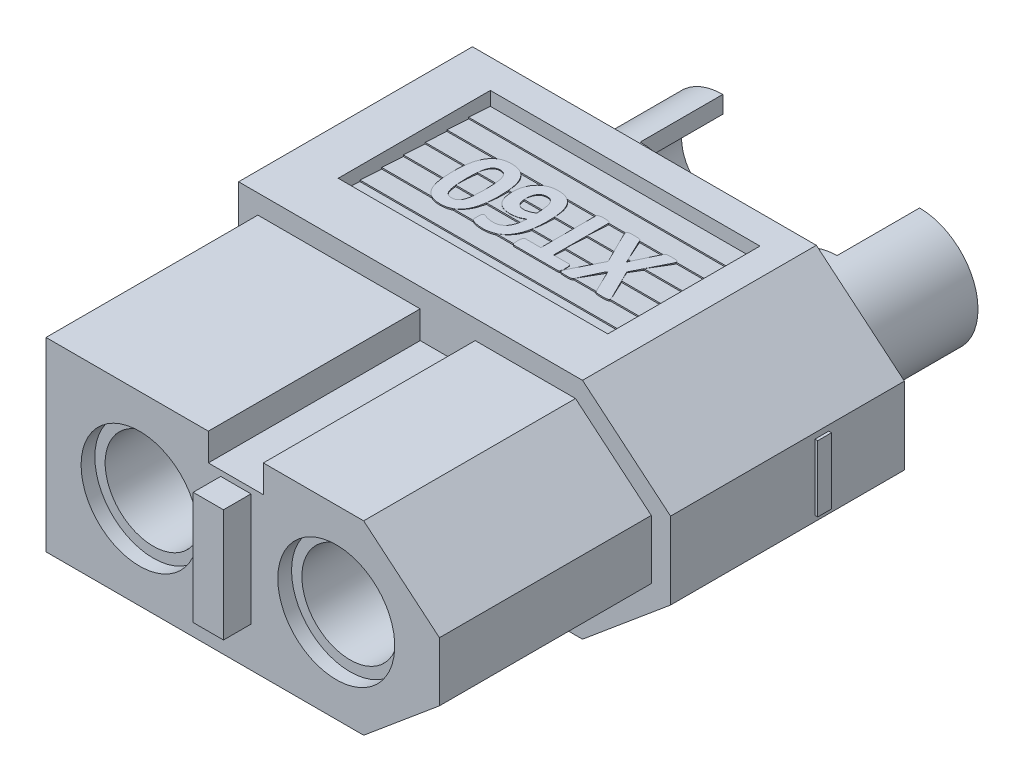
from build123d import *

# Parameters (mm, degrees)
RESSALTO_EXTRUS_O1_DEPTH         = 16.2
ESBO_O3_W                        = 0.5
ESBO_O3_H                        = 2.4
RESSALTO_EXTRUS_O2_DEPTH         = 0.1
RESSALTO_EXTRUS_O2_DEPTH_BACK    = 15.8
ESBO_O4_W                        = 2.4
ESBO_O4_H                        = 0.5
RESSALTO_EXTRUS_O3_DEPTH         = 0.1
ESBO_O5_R                        = 2.925
CORTE_EXTRUS_O2_DEPTH            = 3.5
ESBO_O6_R                        = 2.125
CORTE_EXTRUS_O3_DEPTH            = 21.676934613
ESBO_O7_R                        = 2.125
RESSALTO_EXTRUS_O4_DEPTH         = 5
RESSALTO_EXTRUS_O4_DEPTH_BACK    = 15.7
FURO_DE_DI_METRO_3_0_3_1_D       = 3
FURO_DE_DI_METRO_3_0_3_1_DEPTH   = 3.6
FURO_DE_DI_METRO_3_0_3_1_TIP     = 0.901290929
ESBO_O10_W                       = 2.125
ESBO_O10_H                       = 3
CORTE_EXTRUS_O4_DEPTH            = 28.667715844
CORTE_EXTRUS_O5_START            = -1.7
CORTE_EXTRUS_O5_DEPTH            = 9.8
RESSALTO_EXTRUS_O6_DEPTH         = 0.05
RESSALTO_EXTRUS_O7_DEPTH         = 0.05
ESBO_O2_OUTSIDE_W                = 23.444
ESBO_O2_OUTSIDE_H                = 15.694
CORTE_EXTRUS_O7_DEPTH            = 7.7
ESBO_O16_W                       = 2
ESBO_O16_H                       = 1
CORTE_EXTRUS_O8_DEPTH            = 7.7
ESBO_O17_W                       = 1.1
ESBO_O17_H                       = 4.1
RESSALTO_EXTRUS_O8_DEPTH         = 1
FURO_DE_DI_METRO_3_5_3_5_1_D     = 3.5
FURO_DE_DI_METRO_3_5_3_5_1_DEPTH = 12
FURO_DE_DI_METRO_3_5_3_5_1_TIP   = 1.051506083


with BuildPart() as part:
    # Esboço1 → Ressalto-extrusão1 (new body)
    with BuildSketch(Plane.XY):
        Polygon((0, 0), (0, 4.075), (12.5, 4.075), (15.7, 1.4), (15.7, -1.4), (12.5, -4.075), (0, -4.075), align=None)
    extrude(amount=-RESSALTO_EXTRUS_O1_DEPTH)

    # Esboço3 → Ressalto-extrusão2 (add, two sides)
    with BuildSketch(Plane(origin=(15.7, 0, 0), x_dir=(0, 0, -1), z_dir=(1, 0, 0))) as ressalto_extrus_o2_sk:
        with Locations((13.2, 0)):
            Rectangle(ESBO_O3_W, ESBO_O3_H)
    extrude(amount=RESSALTO_EXTRUS_O2_DEPTH)
    extrude(ressalto_extrus_o2_sk.sketch, amount=-RESSALTO_EXTRUS_O2_DEPTH_BACK)

    # Esboço4 → Ressalto-extrusão3 (add)
    with BuildSketch(Plane.ZY):
        with Locations((-13.2, 0)):
            Rectangle(ESBO_O4_W, ESBO_O4_H)
    extrude(amount=RESSALTO_EXTRUS_O3_DEPTH)

    # Esboço5 → Corte-extrusão2 (cut)
    with BuildSketch(Plane(origin=(0, 0, -16.2), x_dir=(-1, 0, 0), z_dir=(0, 0, -1))):
        with Locations((-4.1, 0)):
            Circle(ESBO_O5_R)
        with Locations((-11.25, 0)):
            Circle(ESBO_O5_R)
    extrude(amount=-CORTE_EXTRUS_O2_DEPTH, mode=Mode.SUBTRACT)

    # Esboço6 → Corte-extrusão3 (cut, through all)
    with BuildSketch(Plane(origin=(0, 0, -12.7), x_dir=(-1, 0, 0), z_dir=(0, 0, -1))):
        with Locations((-11.25, 0)):
            Circle(ESBO_O6_R)
        with Locations((-4.1, 0)):
            Circle(ESBO_O6_R)
    extrude(amount=-CORTE_EXTRUS_O3_DEPTH, mode=Mode.SUBTRACT)

    # Esboço7 → Ressalto-extrusão4 (add, two sides)
    with BuildSketch(Plane(origin=(0, 0, -16.2), x_dir=(-1, 0, 0), z_dir=(0, 0, -1))) as ressalto_extrus_o4_sk:
        with Locations((-11.25, 0)):
            Circle(ESBO_O7_R)
        with Locations((-4.1, 0)):
            Circle(ESBO_O7_R)
    extrude(amount=RESSALTO_EXTRUS_O4_DEPTH)
    extrude(ressalto_extrus_o4_sk.sketch, amount=-RESSALTO_EXTRUS_O4_DEPTH_BACK)

    # Furo de diâmetro Ø3.0 (3)1
    with Locations(Plane(origin=(0, 0, -21.2), x_dir=(-1, 0, 0), z_dir=(0, 0, -1))):
        with Locations((-11.25, 0), (-4.1, 0)):
            Hole(FURO_DE_DI_METRO_3_0_3_1_D / 2, depth=FURO_DE_DI_METRO_3_0_3_1_DEPTH)
            with Locations((0, 0, -(FURO_DE_DI_METRO_3_0_3_1_DEPTH + FURO_DE_DI_METRO_3_0_3_1_TIP / 2))):  # 118° drill point
                Cone(0, FURO_DE_DI_METRO_3_0_3_1_D / 2, FURO_DE_DI_METRO_3_0_3_1_TIP, mode=Mode.SUBTRACT)

    # Esboço10 → Corte-extrusão4 (cut, through all)
    with BuildSketch(Plane(origin=(0, 4.075, 0), x_dir=(1, 0, 0), z_dir=(0, 1, 0))):
        with Locations((5.1625, 19.7)):
            Rectangle(ESBO_O10_W, ESBO_O10_H)
        with Locations((10.1875, 19.7)):
            Rectangle(ESBO_O10_W, ESBO_O10_H)
    extrude(amount=-CORTE_EXTRUS_O4_DEPTH, mode=Mode.SUBTRACT)

    # Esboço12 → Corte-extrusão5 (cut)
    with BuildSketch(Plane.ZY.offset(CORTE_EXTRUS_O5_START)):
        Polygon((-9.62, 4.075), (-15.15, 4.075), (-15.15, 3.575), (-14.36, 3.625), (-14.36, 3.575), (-13.57, 3.625), (-13.57, 3.575), (-12.78, 3.625), (-12.78, 3.575), (-11.99, 3.625), (-11.99, 3.575), (-11.2, 3.625), (-11.2, 3.575), (-10.41, 3.625), (-10.41, 3.575), (-9.62, 3.625), align=None)
    corte_extrus_o5 = extrude(amount=-CORTE_EXTRUS_O5_DEPTH, mode=Mode.SUBTRACT)

    # Espelhar1: Corte-extrusão5 across plane
    add(corte_extrus_o5.mirror(Plane.ZX), mode=Mode.SUBTRACT)

    # Esboço13 → Ressalto-extrusão6 (add)
    with BuildSketch(Plane(origin=(0, 3.575, 0), x_dir=(-1, 0, 0), z_dir=(0, 1, 0))):
        with BuildLine():
            add(Edge.make_bspline(
                [(-8.234641561, -13.445571688), (-8.229912114, -13.456153044), (-8.221000453, -13.476091412), (-8.208478692, -13.504296034), (-8.200539268, -13.529795764), (-8.193533814, -13.551501719), (-8.190606852, -13.570582286), (-8.190490698, -13.587635432), (-8.196029978, -13.602281593), (-8.204820877, -13.614842908), (-8.218088126, -13.624787378), (-8.235701708, -13.631860331), (-8.257272865, -13.637319606), (-8.283106651, -13.641242536), (-8.313646706, -13.643111213), (-8.34918968, -13.644848276), (-8.390224184, -13.645936797), (-8.419343109, -13.646201883), (-8.434845735, -13.646343013)],
                knots=[0, 0, 0, 0, 1.33881063, 2.522710567, 3.55823117, 4.421855077, 5.150490164, 5.783956486, 6.364012369, 6.927396487, 7.534352519, 8.24811931, 9.105929366, 10.100125022, 11.260442172, 12.637334165, 14.209750218, 16, 16, 16, 16], degree=3))
            add(Edge.make_bspline(
                [(-8.434845735, -13.646343013), (-8.45941607, -13.646007312), (-8.502710711, -13.645415784), (-8.560169388, -13.644108333), (-8.603722632, -13.638747313), (-8.636957534, -13.632327533), (-8.661538298, -13.62129635), (-8.679434231, -13.607094039), (-8.690987949, -13.588492014), (-8.696684049, -13.575151575), (-8.699705082, -13.568076225)],
                knots=[0, 0, 0, 0, 1.993677762, 3.512999033, 4.656089022, 5.552580678, 6.245508647, 6.822733668, 7.375614965, 8, 8, 8, 8], degree=3))
            Line((-8.699705082, -13.568076225), (-9.126202359, -12.674246824))
            Line((-9.126202359, -12.674246824), (-9.550998185, -13.568076225))
            add(Edge.make_bspline(
                [(-9.550998185, -13.568076225), (-9.554420482, -13.575156296), (-9.560855848, -13.588469824), (-9.572973852, -13.606730658), (-9.590400819, -13.621679404), (-9.615386313, -13.63210906), (-9.649006335, -13.638918578), (-9.69283172, -13.643968922), (-9.749683634, -13.645447394), (-9.792039641, -13.646020654), (-9.815857532, -13.646343013)],
                knots=[0, 0, 0, 0, 0.639550826, 1.202626028, 1.769676174, 2.478488857, 3.377444042, 4.554208722, 6.062341394, 8, 8, 8, 8], degree=3))
            add(Edge.make_bspline(
                [(-9.815857532, -13.646343013), (-9.830225613, -13.646198262), (-9.857264839, -13.645925857), (-9.895090158, -13.644886263), (-9.927788964, -13.643062345), (-9.955524818, -13.641330223), (-9.978882569, -13.637259243), (-9.998091686, -13.631952073), (-10.013573976, -13.624632212), (-10.025108673, -13.614746389), (-10.031959847, -13.601974011), (-10.036249426, -13.587467177), (-10.035705984, -13.570541497), (-10.032114996, -13.55148655), (-10.024728617, -13.529689189), (-10.015315431, -13.504435401), (-10.002587861, -13.475953754), (-9.992874513, -13.456125899), (-9.987704174, -13.445571688)],
                knots=[0, 0, 0, 0, 1.743948978, 3.281929376, 4.591588072, 5.719618763, 6.651354855, 7.464517483, 8.131494618, 8.716472262, 9.271430783, 9.867110125, 10.532506743, 11.302095744, 12.216435998, 13.320169609, 14.573547416, 16, 16, 16, 16], degree=3))
            Line((-9.987704174, -13.445571688), (-9.443806715, -12.364015426))
            Line((-9.443806715, -12.364015426), (-9.949137931, -11.347681488))
            add(Edge.make_bspline(
                [(-9.949137931, -11.347681488), (-9.954164514, -11.336763312), (-9.963626085, -11.316211953), (-9.975233503, -11.286701032), (-9.985307445, -11.261179787), (-9.992096331, -11.238841367), (-9.996985023, -11.21935776), (-9.996364215, -11.202215642), (-9.99249125, -11.187523225), (-9.983979844, -11.175352273), (-9.970702, -11.166484928), (-9.953902201, -11.158918283), (-9.932679067, -11.154320623), (-9.907258464, -11.150985155), (-9.876940002, -11.148999489), (-9.841213652, -11.147101222), (-9.799785428, -11.146975079), (-9.770295344, -11.146562515), (-9.754605263, -11.146343013)],
                knots=[0, 0, 0, 0, 1.381015555, 2.599495016, 3.644671344, 4.531245376, 5.285471223, 5.937655438, 6.480840598, 7.011274188, 7.602323543, 8.29283132, 9.120186307, 10.085039733, 11.239867224, 12.610244907, 14.196494385, 16, 16, 16, 16], degree=3))
            add(Edge.make_bspline(
                [(-9.754605263, -11.146343013), (-9.741558686, -11.146222788), (-9.716782999, -11.145994479), (-9.681822233, -11.147509103), (-9.651171449, -11.148360726), (-9.617850166, -11.150555873), (-9.583543752, -11.154240133), (-9.549847026, -11.161459034), (-9.524097746, -11.170598647), (-9.507151713, -11.18604274), (-9.495569929, -11.204494949), (-9.489213995, -11.217916691), (-9.485775862, -11.225176951)],
                knots=[0, 0, 0, 0, 1.305784148, 2.479707747, 3.50232644, 4.374698542, 5.823003153, 6.947851878, 7.830021634, 8.513661778, 9.195991011, 10, 10, 10, 10], degree=3))
            Line((-9.485775862, -11.225176951), (-9.087636116, -12.044142468))
            Line((-9.087636116, -12.044142468), (-8.699705082, -11.225176951))
            add(Edge.make_bspline(
                [(-8.699705082, -11.225176951), (-8.696208396, -11.217958809), (-8.689789069, -11.204707514), (-8.678987166, -11.185825159), (-8.662466375, -11.171432078), (-8.639135192, -11.161047964), (-8.607924012, -11.15443418), (-8.566580132, -11.149301561), (-8.512000017, -11.146989484), (-8.470764909, -11.146577323), (-8.447323049, -11.146343013)],
                knots=[0, 0, 0, 0, 0.679172131, 1.24684586, 1.824338574, 2.496513618, 3.384423394, 4.51265828, 6.017471582, 8, 8, 8, 8], degree=3))
            add(Edge.make_bspline(
                [(-8.447323049, -11.146343013), (-8.433523531, -11.146564201), (-8.407247474, -11.146985373), (-8.37035379, -11.147085854), (-8.338029755, -11.149027992), (-8.310179351, -11.1510601), (-8.286413928, -11.154219396), (-8.266298471, -11.159046466), (-8.250419325, -11.166827939), (-8.238191654, -11.176899845), (-8.230116772, -11.189188032), (-8.225150971, -11.20379148), (-8.224991298, -11.220836902), (-8.228948714, -11.239976481), (-8.23555094, -11.261794984), (-8.243997203, -11.287162685), (-8.254845117, -11.316345412), (-8.263479068, -11.336751762), (-8.268103448, -11.347681488)],
                knots=[0, 0, 0, 0, 1.674249213, 3.187985698, 4.474062261, 5.601505857, 6.57446085, 7.381029521, 8.09893875, 8.700896638, 9.279693563, 9.859851831, 10.548217011, 11.317405471, 12.224627673, 13.312424426, 14.560523399, 16, 16, 16, 16], degree=3))
            Line((-8.268103448, -11.347681488), (-8.773434664, -12.35834392))
            Line((-8.773434664, -12.35834392), (-8.234641561, -13.445571688))
        make_face()
        with BuildLine():
            add(Edge.make_bspline(
                [(-6.479764065, -11.364696007), (-6.479952581, -11.381903542), (-6.48029899, -11.413523441), (-6.48341703, -11.456960547), (-6.489204855, -11.492569091), (-6.495811812, -11.521038206), (-6.505603936, -11.542938637), (-6.518024204, -11.557935573), (-6.532518904, -11.56780598), (-6.543152743, -11.568899092), (-6.548389292, -11.569437387)],
                knots=[0, 0, 0, 0, 1.770192918, 3.252837809, 4.474195287, 5.478923574, 6.253187412, 6.915561504, 7.465976934, 8, 8, 8, 8], degree=3))
            Line((-6.548389292, -11.569437387), (-7.116674229, -11.569437387))
            Line((-7.116674229, -11.569437387), (-7.116674229, -13.565807623))
            add(Edge.make_bspline(
                [(-7.116674229, -13.565807623), (-7.117228597, -13.571945061), (-7.118341807, -13.584269468), (-7.127428288, -13.601786712), (-7.144220624, -13.615719697), (-7.167710509, -13.627021375), (-7.199523817, -13.634947595), (-7.239867569, -13.641788815), (-7.290547162, -13.645274662), (-7.327651728, -13.645963771), (-7.348071688, -13.646343013)],
                knots=[0, 0, 0, 0, 0.55099044, 1.106427587, 1.720983746, 2.48178517, 3.435218407, 4.660203207, 6.161991303, 8, 8, 8, 8], degree=3))
            add(Edge.make_bspline(
                [(-7.348071688, -13.646343013), (-7.368489053, -13.645949995), (-7.405777292, -13.645232225), (-7.456673966, -13.641874277), (-7.497321774, -13.634790597), (-7.529307091, -13.627297057), (-7.552592782, -13.615549041), (-7.569288598, -13.601800063), (-7.578367211, -13.584266302), (-7.579481428, -13.571944008), (-7.580036298, -13.565807623)],
                knots=[0, 0, 0, 0, 1.833840391, 3.349143282, 4.571350014, 5.538985911, 6.282919168, 6.896081612, 7.450259118, 8, 8, 8, 8], degree=3))
            Line((-7.580036298, -13.565807623), (-7.580036298, -11.569437387))
            Line((-7.580036298, -11.569437387), (-8.148321234, -11.569437387))
            add(Edge.make_bspline(
                [(-8.148321234, -11.569437387), (-8.1539353, -11.568946373), (-8.164948634, -11.567983132), (-8.179836964, -11.558248445), (-8.190916127, -11.542485604), (-8.201009403, -11.52112794), (-8.207465206, -11.492536286), (-8.21330788, -11.456972208), (-8.216406773, -11.413519579), (-8.216756267, -11.381902181), (-8.216946461, -11.364696007)],
                knots=[0, 0, 0, 0, 0.571323018, 1.120786752, 1.757624666, 2.530549763, 3.533540823, 4.752786512, 6.232867835, 8, 8, 8, 8], degree=3))
            add(Edge.make_bspline(
                [(-8.216946461, -11.364696007), (-8.216767768, -11.34692021), (-8.216440394, -11.314354056), (-8.213226949, -11.269611506), (-8.207725367, -11.233383291), (-8.20080363, -11.204762743), (-8.191287548, -11.183614648), (-8.179599375, -11.168727226), (-8.164803722, -11.159803236), (-8.153919584, -11.158779661), (-8.148321234, -11.158253176)],
                knots=[0, 0, 0, 0, 1.808148228, 3.312618493, 4.558353409, 5.533285709, 6.298922035, 6.899726023, 7.434064622, 8, 8, 8, 8], degree=3))
            Line((-8.148321234, -11.158253176), (-6.548389292, -11.158253176))
            add(Edge.make_bspline(
                [(-6.548389292, -11.158253176), (-6.543166887, -11.158822375), (-6.532660107, -11.159967528), (-6.518239485, -11.169045028), (-6.505244254, -11.183137353), (-6.49601287, -11.204856282), (-6.488944489, -11.233347393), (-6.48349821, -11.269624422), (-6.480265258, -11.314349754), (-6.479941037, -11.346918691), (-6.479764065, -11.364696007)],
                knots=[0, 0, 0, 0, 0.528901719, 1.064079353, 1.691187204, 2.458025756, 3.434488925, 4.682179932, 6.189012562, 8, 8, 8, 8], degree=3))
        make_face()
        with BuildLine():
            add(Edge.make_bspline(
                [(-4.844555354, -12.808094374), (-4.845247025, -12.838744217), (-4.846612474, -12.899251075), (-4.856275338, -12.988233606), (-4.872679949, -13.073820368), (-4.895953873, -13.155374701), (-4.925117155, -13.232653385), (-4.961282618, -13.304391043), (-5.002446968, -13.371456777), (-5.051124238, -13.432064114), (-5.104840545, -13.487492071), (-5.165252856, -13.536042443), (-5.231195633, -13.578629077), (-5.302881701, -13.615100212), (-5.380529825, -13.644444145), (-5.464224836, -13.664259535), (-5.553460591, -13.677335616), (-5.614885533, -13.678591325), (-5.646506352, -13.67923775)],
                knots=[0, 0, 0, 0, 1.10131412, 2.174140236, 3.212046795, 4.22920211, 5.218361909, 6.175388662, 7.112262148, 8.040623825, 8.963000514, 9.88076228, 10.819186251, 11.779270414, 12.766024375, 13.794191409, 14.864476351, 16, 16, 16, 16], degree=3))
            add(Edge.make_bspline(
                [(-5.646506352, -13.67923775), (-5.672045734, -13.678869754), (-5.721537896, -13.678156624), (-5.793253674, -13.670756192), (-5.859789209, -13.658257146), (-5.921656832, -13.641492467), (-5.97856069, -13.618979437), (-6.031835642, -13.592865549), (-6.08110806, -13.562363994), (-6.126246028, -13.527477715), (-6.167456271, -13.488525554), (-6.204783911, -13.445650438), (-6.237810544, -13.398487157), (-6.26758624, -13.348005903), (-6.292618909, -13.293059721), (-6.315967517, -13.235427876), (-6.33652839, -13.174283157), (-6.36003645, -13.086844775), (-6.382763535, -12.969639749), (-6.399809764, -12.820208412), (-6.408375812, -12.660363043), (-6.409376493, -12.550428328), (-6.409891107, -12.493892922)],
                knots=[0, 0, 0, 0, 0.94765967, 1.836447168, 2.671778883, 3.458266774, 4.211402354, 4.93940858, 5.657884628, 6.358212394, 7.053105983, 7.759383965, 8.46412671, 9.187383544, 9.931310937, 10.702660795, 11.494793595, 12.323735541, 14.061720359, 15.919867049, 17.901736725, 20, 20, 20, 20], degree=3))
            add(Edge.make_bspline(
                [(-6.409891107, -12.493892922), (-6.409111479, -12.444351851), (-6.40751516, -12.342914634), (-6.398296575, -12.188722943), (-6.379642121, -12.03241523), (-6.354053618, -11.903223438), (-6.326053677, -11.802303824), (-6.301145096, -11.728321145), (-6.272716985, -11.655944871), (-6.240622367, -11.585636923), (-6.204037281, -11.51831458), (-6.16258064, -11.454919209), (-6.115656325, -11.396276286), (-6.064197727, -11.341635694), (-6.007056161, -11.29202333), (-5.94441976, -11.247327276), (-5.875392712, -11.209248367), (-5.801312147, -11.174990875), (-5.720255341, -11.148506057), (-5.63233357, -11.129199885), (-5.537335641, -11.117986812), (-5.471664865, -11.116489251), (-5.437794918, -11.115716878)],
                knots=[0, 0, 0, 0, 1.551011205, 3.175754089, 4.833311519, 6.475679743, 7.292710589, 8.110576988, 8.918359717, 9.726055718, 10.528552722, 11.314823521, 12.094001482, 12.876856948, 13.661321481, 14.459397945, 15.280853931, 16.12576799, 17.011009771, 17.944382583, 18.939807688, 20, 20, 20, 20], degree=3))
            add(Edge.make_bspline(
                [(-5.437794918, -11.115716878), (-5.415464757, -11.116119973), (-5.370702147, -11.116928007), (-5.304166962, -11.124501607), (-5.239694304, -11.133367375), (-5.179993919, -11.146100086), (-5.126814374, -11.159440188), (-5.083037153, -11.175745844), (-5.049919244, -11.190634637), (-5.027663424, -11.204945901), (-5.014266481, -11.219508865), (-5.005803825, -11.234666003), (-4.999597723, -11.251019614), (-4.994372917, -11.26901591), (-4.990278959, -11.289860373), (-4.988310764, -11.314751727), (-4.987312957, -11.344646929), (-4.9870527, -11.36639614), (-4.986910163, -11.378307623)],
                knots=[0, 0, 0, 0, 1.765874355, 3.539837499, 5.29331737, 6.912486512, 8.367265213, 9.625919252, 10.602679397, 11.237403907, 11.703219776, 12.152162367, 12.602100397, 13.08489485, 13.633411172, 14.279314959, 15.057625196, 16, 16, 16, 16], degree=3))
            add(Edge.make_bspline(
                [(-4.986910163, -11.378307623), (-4.986915483, -11.396276471), (-4.986925231, -11.429206148), (-4.989441238, -11.473605088), (-4.991941835, -11.509308686), (-4.998255435, -11.536040442), (-5.005634482, -11.55664047), (-5.01768581, -11.56959271), (-5.031865418, -11.578246263), (-5.042547572, -11.57879206), (-5.048162432, -11.579078947)],
                knots=[0, 0, 0, 0, 1.876905788, 3.439613972, 4.650533844, 5.604148176, 6.312332604, 6.89971502, 7.421657351, 8, 8, 8, 8], degree=3))
            add(Edge.make_bspline(
                [(-5.048162432, -11.579078947), (-5.056152678, -11.578185642), (-5.074749872, -11.576106485), (-5.104948677, -11.565924298), (-5.141775898, -11.552592934), (-5.185598468, -11.537746817), (-5.237332484, -11.523356145), (-5.297450626, -11.510829874), (-5.367034307, -11.502088108), (-5.416591394, -11.501254624), (-5.442899274, -11.50081216)],
                knots=[0, 0, 0, 0, 0.475638614, 1.107042779, 1.880026666, 2.801778904, 3.848964285, 5.062645579, 6.440675709, 8, 8, 8, 8], degree=3))
            add(Edge.make_bspline(
                [(-5.442899274, -11.50081216), (-5.465817802, -11.501374484), (-5.510040369, -11.50245952), (-5.573600554, -11.513320605), (-5.631532579, -11.531618741), (-5.684177415, -11.55647825), (-5.730962306, -11.588558693), (-5.774066052, -11.624619941), (-5.81132997, -11.667158205), (-5.844490619, -11.713876103), (-5.872835841, -11.765396675), (-5.896989227, -11.820934395), (-5.917641849, -11.880433126), (-5.939361485, -11.965621491), (-5.95662933, -12.07883929), (-5.960455015, -12.171119195), (-5.962409256, -12.218257713)],
                knots=[0, 0, 0, 0, 0.962219322, 1.856655383, 2.698144689, 3.508120587, 4.292336159, 5.075424752, 5.862971534, 6.660705278, 7.478432318, 8.328424745, 9.202529248, 10.121421552, 12.01874047, 14, 14, 14, 14], degree=3))
            add(Edge.make_bspline(
                [(-5.962409256, -12.218257713), (-5.948705374, -12.209216367), (-5.919946224, -12.190242076), (-5.873096067, -12.163862359), (-5.82149294, -12.138826626), (-5.764644654, -12.117871226), (-5.703195854, -12.100361931), (-5.636938355, -12.086301845), (-5.5660989, -12.075934798), (-5.517235445, -12.075163254), (-5.492241379, -12.074768603)],
                knots=[0, 0, 0, 0, 0.78917907, 1.656181786, 2.583148547, 3.543818215, 4.565141387, 5.652638214, 6.799304831, 8, 8, 8, 8], degree=3))
            add(Edge.make_bspline(
                [(-5.492241379, -12.074768603), (-5.464610786, -12.075422907), (-5.411251302, -12.076686482), (-5.334103949, -12.086337051), (-5.263118639, -12.102470556), (-5.198256069, -12.125601102), (-5.138991557, -12.153616625), (-5.085650657, -12.188211663), (-5.037600875, -12.22795976), (-4.995638574, -12.273632751), (-4.958889478, -12.324344971), (-4.927177103, -12.379806858), (-4.90093147, -12.440721882), (-4.880202569, -12.506345811), (-4.864693261, -12.576467827), (-4.852544445, -12.650071848), (-4.845813158, -12.727810889), (-4.844982054, -12.780858844), (-4.844555354, -12.808094374)],
                knots=[0, 0, 0, 0, 1.185476522, 2.289361458, 3.330402215, 4.302896258, 5.239078869, 6.136970646, 7.024058495, 7.908173521, 8.79094751, 9.706658425, 10.644105674, 11.631910237, 12.65532036, 13.723663453, 14.831298352, 16, 16, 16, 16], degree=3))
        make_face()
        with BuildLine():
            add(Edge.make_bspline(
                [(-5.297708711, -12.855735027), (-5.298355421, -12.825061911), (-5.299566741, -12.767609601), (-5.311337039, -12.687156616), (-5.330852539, -12.617833028), (-5.356776743, -12.56876529), (-5.382220717, -12.535833051), (-5.404405481, -12.515072385), (-5.429147682, -12.496910224), (-5.457312983, -12.482954559), (-5.488127378, -12.471644525), (-5.521865623, -12.46281878), (-5.558874604, -12.458711163), (-5.584491022, -12.457975516), (-5.597731397, -12.457595281)],
                knots=[0, 0, 0, 0, 1.925590605, 3.606729444, 5.094508301, 6.428034127, 7.062334218, 7.700734116, 8.33023602, 8.983484412, 9.667319134, 10.390249713, 11.167967283, 12, 12, 12, 12], degree=3))
            add(Edge.make_bspline(
                [(-5.597731397, -12.457595281), (-5.613831938, -12.457981146), (-5.646202231, -12.458756929), (-5.693976134, -12.466621891), (-5.741297754, -12.477888378), (-5.787126477, -12.494006349), (-5.832242753, -12.512487237), (-5.875016027, -12.534782951), (-5.915841632, -12.558881719), (-5.941348655, -12.576902403), (-5.953901996, -12.585771325)],
                knots=[0, 0, 0, 0, 1.003605369, 2.017758243, 3.01322247, 4.035163496, 5.044917746, 6.052396451, 7.041482352, 8, 8, 8, 8], degree=3))
            add(Edge.make_bspline(
                [(-5.953901996, -12.585771325), (-5.953738845, -12.618480644), (-5.953425609, -12.681279395), (-5.949573246, -12.77115102), (-5.94273085, -12.852485608), (-5.93395734, -12.925410624), (-5.92221038, -12.990625759), (-5.907223779, -13.048428989), (-5.89141713, -13.099800439), (-5.871968607, -13.144121534), (-5.849871156, -13.181828529), (-5.825285309, -13.21370498), (-5.797816018, -13.23972106), (-5.767321144, -13.259696406), (-5.734388336, -13.274728481), (-5.698959689, -13.284662405), (-5.661295793, -13.291109954), (-5.63537983, -13.291990466), (-5.622118875, -13.292441016)],
                knots=[0, 0, 0, 0, 1.792178445, 3.440810432, 4.927313934, 6.263548764, 7.464311732, 8.554687037, 9.53417516, 10.406093985, 11.200210032, 11.923394166, 12.604947615, 13.262869107, 13.911841104, 14.580600631, 15.273706656, 16, 16, 16, 16], degree=3))
            add(Edge.make_bspline(
                [(-5.622118875, -13.292441016), (-5.609058423, -13.291927459), (-5.583757494, -13.290932587), (-5.546883676, -13.285462406), (-5.512644327, -13.275038671), (-5.470262136, -13.256338212), (-5.423274503, -13.222135383), (-5.376911642, -13.16840422), (-5.341536124, -13.102980923), (-5.316447569, -13.027712024), (-5.300226045, -12.944329052), (-5.29856505, -12.885872675), (-5.297708711, -12.855735027)],
                knots=[0, 0, 0, 0, 0.641224683, 1.242191304, 1.823353171, 2.392316502, 3.509633759, 4.640732345, 5.849129079, 7.134193297, 8.522510647, 10, 10, 10, 10], degree=3))
        make_face(mode=Mode.SUBTRACT)
        with BuildLine():
            add(Edge.make_bspline(
                [(-3.11746824, -12.386701452), (-3.118051844, -12.435106864), (-3.119187955, -12.529338284), (-3.126881805, -12.667352054), (-3.141241545, -12.797881836), (-3.159964139, -12.921294814), (-3.185411793, -13.036323407), (-3.216588532, -13.143347656), (-3.256615384, -13.240850856), (-3.302287754, -13.330230177), (-3.355612705, -13.409937458), (-3.416425654, -13.480446259), (-3.485263452, -13.540591417), (-3.561723506, -13.591334238), (-3.646311017, -13.631590004), (-3.74015479, -13.658877257), (-3.842390876, -13.676361325), (-3.913670883, -13.678255877), (-3.950612523, -13.67923775)],
                knots=[0, 0, 0, 0, 1.331714136, 2.592464548, 3.800914866, 4.943304834, 6.024741112, 7.040005629, 8.005827517, 8.920038389, 9.797084602, 10.637656394, 11.474309038, 12.303752944, 13.155259566, 14.040502508, 14.984469079, 16, 16, 16, 16], degree=3))
            add(Edge.make_bspline(
                [(-3.950612523, -13.67923775), (-3.987925423, -13.678215432), (-4.059539821, -13.676253306), (-4.161996374, -13.659539217), (-4.254654396, -13.632966746), (-4.337157484, -13.594121104), (-4.410822788, -13.545665929), (-4.474961026, -13.486179078), (-4.53278151, -13.41875554), (-4.581228314, -13.340736734), (-4.622835206, -13.253743897), (-4.656873098, -13.157554606), (-4.685449777, -13.052774236), (-4.706359958, -12.939055806), (-4.72214234, -12.816918135), (-4.732289533, -12.686857114), (-4.739518269, -12.548987571), (-4.740267624, -12.4545808), (-4.740653358, -12.405984574)],
                knots=[0, 0, 0, 0, 1.046066533, 2.007708451, 2.903737557, 3.741199507, 4.556040875, 5.366886076, 6.187145389, 7.040475504, 7.934698051, 8.887526005, 9.898691685, 10.978297228, 12.128103782, 13.351984046, 14.636924245, 16, 16, 16, 16], degree=3))
            add(Edge.make_bspline(
                [(-4.740653358, -12.405984574), (-4.740151285, -12.35795109), (-4.739170035, -12.264074476), (-4.730300275, -12.126910394), (-4.71714708, -11.996424103), (-4.697499664, -11.873091127), (-4.671655709, -11.757457308), (-4.639678789, -11.650024037), (-4.5999819, -11.551951788), (-4.554084655, -11.462484122), (-4.500832648, -11.382573185), (-4.439589167, -11.312398446), (-4.370419417, -11.252677225), (-4.294147488, -11.201897164), (-4.209537824, -11.161663757), (-4.115875262, -11.134450162), (-4.014222652, -11.116909881), (-3.943506165, -11.115001937), (-3.906941924, -11.114015426)],
                knots=[0, 0, 0, 0, 1.32239156, 2.584481369, 3.783013823, 4.932291786, 6.020825522, 7.043403636, 8.014836354, 8.929792713, 9.807554109, 10.652234463, 11.486148566, 12.316268837, 13.168469815, 14.054434623, 14.994037682, 16, 16, 16, 16], degree=3))
            add(Edge.make_bspline(
                [(-3.906941924, -11.114015426), (-3.869648343, -11.115132161), (-3.798100753, -11.117274611), (-3.695364398, -11.132740235), (-3.602916537, -11.160657993), (-3.519828368, -11.198807711), (-3.446399956, -11.248082215), (-3.380463468, -11.305890952), (-3.323973019, -11.374768583), (-3.275075651, -11.452425518), (-3.233792053, -11.539406053), (-3.199177976, -11.635341355), (-3.171737987, -11.74036778), (-3.151071585, -11.85419546), (-3.136434424, -11.976230899), (-3.124752055, -12.106144019), (-3.118911693, -12.243914513), (-3.117957533, -12.338300328), (-3.11746824, -12.386701452)],
                knots=[0, 0, 0, 0, 1.045902831, 2.006560538, 2.903970151, 3.746105489, 4.56081934, 5.375878205, 6.196660228, 7.049856803, 7.94393941, 8.891632579, 9.906387228, 10.984846666, 12.133800561, 13.352654929, 14.642439237, 16, 16, 16, 16], degree=3))
        make_face()
        with BuildLine():
            add(Edge.make_bspline(
                [(-3.58253176, -12.41165608), (-3.582632227, -12.383108616), (-3.582826527, -12.327898802), (-3.584556338, -12.24754172), (-3.587332422, -12.172477342), (-3.591190326, -12.102313588), (-3.596600678, -12.037126681), (-3.601590621, -11.976094404), (-3.609976057, -11.919850481), (-3.620687665, -11.85280788), (-3.636758403, -11.77877234), (-3.661367241, -11.701166165), (-3.690688913, -11.63747601), (-3.727222675, -11.588002598), (-3.769498616, -11.551521367), (-3.817649774, -11.527810607), (-3.870510753, -11.514711141), (-3.907246375, -11.513025845), (-3.926225045, -11.512155172)],
                knots=[0, 0, 0, 0, 1.284431786, 2.484047002, 3.616142059, 4.664071033, 5.645250234, 6.559356666, 7.418250505, 8.202740236, 9.614323635, 10.822083543, 11.86068477, 12.753813116, 13.56848039, 14.348298709, 15.146684002, 16, 16, 16, 16], degree=3))
            add(Edge.make_bspline(
                [(-3.926225045, -11.512155172), (-3.94272449, -11.512773786), (-3.974738283, -11.513974078), (-4.020479085, -11.524198551), (-4.061709768, -11.541583746), (-4.0986431, -11.565592514), (-4.130700128, -11.597385469), (-4.160082476, -11.635008682), (-4.184506144, -11.680358905), (-4.206235997, -11.731800528), (-4.223990686, -11.79006314), (-4.239358744, -11.854624979), (-4.250824065, -11.926150865), (-4.260591563, -12.004068284), (-4.266898638, -12.088886585), (-4.272215001, -12.180199726), (-4.274814622, -12.278361062), (-4.275325751, -12.346054678), (-4.275589837, -12.381029946)],
                knots=[0, 0, 0, 0, 0.762118583, 1.478735069, 2.152336062, 2.821329334, 3.501193893, 4.230120737, 5.02038063, 5.874145257, 6.808384398, 7.832217387, 8.939929293, 10.155058802, 11.461419548, 12.870631504, 14.383148819, 16, 16, 16, 16], degree=3))
            add(Edge.make_bspline(
                [(-4.275589837, -12.381029946), (-4.275474704, -12.423193699), (-4.275254708, -12.503760971), (-4.27082077, -12.618892187), (-4.265835085, -12.722786573), (-4.257067114, -12.815628103), (-4.246923143, -12.898487727), (-4.232443531, -12.97184427), (-4.21653428, -13.03664949), (-4.197393466, -13.092768137), (-4.175152616, -13.140509635), (-4.150328431, -13.180969635), (-4.121951294, -13.213546827), (-4.090574604, -13.23907326), (-4.055402457, -13.256441996), (-4.017820774, -13.269923514), (-3.976579034, -13.27696989), (-3.948176802, -13.278198671), (-3.933598004, -13.278829401)],
                knots=[0, 0, 0, 0, 1.898873998, 3.628403222, 5.188934062, 6.582708822, 7.827907354, 8.94675174, 9.948352832, 10.831595324, 11.612452879, 12.316456424, 12.962066015, 13.549833112, 14.124880791, 14.720002925, 15.342980538, 16, 16, 16, 16], degree=3))
            add(Edge.make_bspline(
                [(-3.933598004, -13.278829401), (-3.911923762, -13.277656011), (-3.870436452, -13.275409991), (-3.811642651, -13.257531529), (-3.761118676, -13.226329249), (-3.717280064, -13.183429289), (-3.68113515, -13.127888058), (-3.652214417, -13.060264127), (-3.627852002, -12.981576269), (-3.609965107, -12.890833613), (-3.595569955, -12.788623314), (-3.587896668, -12.673973624), (-3.583553211, -12.547053145), (-3.582882644, -12.458166989), (-3.58253176, -12.41165608)],
                knots=[0, 0, 0, 0, 0.751197133, 1.437888758, 2.106068794, 2.792541115, 3.549301373, 4.389082058, 5.337144767, 6.40224806, 7.594198163, 8.916220199, 10.386369622, 12, 12, 12, 12], degree=3))
        make_face(mode=Mode.SUBTRACT)
    extrude(amount=RESSALTO_EXTRUS_O6_DEPTH)

    # Esboço14 → Ressalto-extrusão7 (add)
    with BuildSketch(Plane(origin=(0, -3.575, 0), x_dir=(-1, 0, 0), z_dir=(0, 1, 0))):
        with BuildLine():
            add(Edge.make_bspline(
                [(-5.47488657, -10.871252269), (-5.474722568, -10.878993167), (-5.474314418, -10.89825791), (-5.470884957, -10.931172474), (-5.466829831, -10.971685719), (-5.459930441, -11.016863984), (-5.451262344, -11.065433416), (-5.439136975, -11.114971543), (-5.426514751, -11.164127603), (-5.410206937, -11.208864298), (-5.392278374, -11.249022453), (-5.369361189, -11.279316016), (-5.345140954, -11.304036801), (-5.324811163, -11.307061216), (-5.315426497, -11.30845735)],
                knots=[0, 0, 0, 0, 0.569387536, 1.417032566, 2.432701303, 3.564649302, 4.778070122, 6.060490265, 7.316356391, 8.506785177, 9.565983581, 10.524288402, 11.31878, 12, 12, 12, 12], degree=3))
            Line((-5.315426497, -11.30845735), (-4.562295826, -11.30845735))
            Line((-4.562295826, -11.30845735), (-4.080921053, -13.943666062))
            add(Edge.make_bspline(
                [(-4.080921053, -13.943666062), (-4.078049987, -13.951824904), (-4.072202689, -13.968441448), (-4.05586764, -13.990959212), (-4.030744426, -14.009757156), (-3.996352227, -14.024194158), (-3.95204821, -14.034677522), (-3.897339588, -14.043995403), (-3.829448199, -14.048564048), (-3.779722068, -14.049471679), (-3.752268603, -14.049972777)],
                knots=[0, 0, 0, 0, 0.562754615, 1.146122955, 1.784880109, 2.58721322, 3.563293576, 4.752564911, 6.207112733, 8, 8, 8, 8], degree=3))
            add(Edge.make_bspline(
                [(-3.752268603, -14.049972777), (-3.725319414, -14.04944941), (-3.676350759, -14.048498413), (-3.610134329, -14.044196717), (-3.55845671, -14.034841166), (-3.519068606, -14.025036677), (-3.491672885, -14.009604884), (-3.473878659, -13.990620428), (-3.466967167, -13.967237653), (-3.468497633, -13.951660697), (-3.469283122, -13.943666062)],
                knots=[0, 0, 0, 0, 1.911196729, 3.472784822, 4.694253329, 5.634626498, 6.332407189, 6.896531254, 7.433661504, 8, 8, 8, 8], degree=3))
            Line((-3.469283122, -13.943666062), (-3.951406534, -11.30845735))
            Line((-3.951406534, -11.30845735), (-3.205013612, -11.30845735))
            add(Edge.make_bspline(
                [(-3.205013612, -11.30845735), (-3.194598819, -11.307559173), (-3.174588058, -11.305833435), (-3.15470698, -11.279246766), (-3.146397167, -11.245222766), (-3.145577263, -11.219443584), (-3.145122505, -11.205145191)],
                knots=[0, 0, 0, 0, 0.889821815, 1.709684739, 2.729679269, 4, 4, 4, 4], degree=3))
            add(Edge.make_bspline(
                [(-3.145122505, -11.205145191), (-3.145333103, -11.196909509), (-3.145837751, -11.177174675), (-3.147851926, -11.143381166), (-3.153644019, -11.102551586), (-3.15973239, -11.056186324), (-3.16989381, -11.007163531), (-3.180433909, -10.95644602), (-3.194392868, -10.907661424), (-3.210208799, -10.862343227), (-3.230057237, -10.824015907), (-3.251462939, -10.793381697), (-3.275721726, -10.770406953), (-3.295506399, -10.767176264), (-3.304582577, -10.765694192)],
                knots=[0, 0, 0, 0, 0.603562236, 1.446291891, 2.478015879, 3.623340615, 4.871035952, 6.144054999, 7.417205306, 8.585498042, 9.656636744, 10.559854985, 11.339336372, 12, 12, 12, 12], degree=3))
            Line((-3.304582577, -10.765694192), (-5.417241379, -10.765694192))
            add(Edge.make_bspline(
                [(-5.417241379, -10.765694192), (-5.426021044, -10.766945731), (-5.444266447, -10.769546607), (-5.462772826, -10.795156836), (-5.473521221, -10.829335295), (-5.474394038, -10.856131249), (-5.47488657, -10.871252269)],
                knots=[0, 0, 0, 0, 0.769617577, 1.599375678, 2.64532208, 4, 4, 4, 4], degree=3))
        make_face()
        with BuildLine():
            add(Edge.make_bspline(
                [(-7.798362069, -11.113811252), (-7.798231436, -11.12354962), (-7.797936183, -11.145560039), (-7.794465971, -11.181476908), (-7.790313331, -11.222977063), (-7.783664337, -11.267707758), (-7.774653403, -11.314164887), (-7.763685503, -11.360118712), (-7.751300331, -11.40432106), (-7.736734567, -11.44388848), (-7.720521764, -11.478755331), (-7.701702289, -11.504992196), (-7.682684947, -11.526498187), (-7.666446234, -11.529464114), (-7.659115245, -11.530803085)],
                knots=[0, 0, 0, 0, 0.763872462, 1.726485752, 2.829243498, 4.036555683, 5.273047091, 6.541071871, 7.743292575, 8.870803578, 9.851566093, 10.737008226, 11.42982069, 12, 12, 12, 12], degree=3))
            add(Edge.make_bspline(
                [(-7.659115245, -11.530803085), (-7.65283626, -11.529998195), (-7.638714668, -11.528187979), (-7.61586719, -11.520166043), (-7.589829713, -11.506229454), (-7.547956763, -11.47931538), (-7.486049388, -11.43786025), (-7.413466614, -11.399050951), (-7.346580208, -11.364680104), (-7.288112116, -11.340410348), (-7.224393037, -11.317272037), (-7.15540878, -11.295268055), (-7.080033832, -11.276391372), (-6.998056912, -11.26192493), (-6.909093834, -11.255113346), (-6.847848408, -11.253759055), (-6.816147913, -11.253058076)],
                knots=[0, 0, 0, 0, 0.294208217, 0.661681512, 1.11903447, 1.667173581, 2.979109855, 4.586359241, 5.495809246, 6.479993016, 7.531377717, 8.65232186, 9.850138254, 11.14732419, 12.523461389, 14, 14, 14, 14], degree=3))
            add(Edge.make_bspline(
                [(-6.816147913, -11.253058076), (-6.783914554, -11.253672562), (-6.72071138, -11.254877446), (-6.62805261, -11.267447938), (-6.539341479, -11.286744906), (-6.454645068, -11.313667908), (-6.374431935, -11.347896709), (-6.297217204, -11.386738834), (-6.224204171, -11.43262809), (-6.154348061, -11.483594655), (-6.088546738, -11.539676116), (-6.027008208, -11.600712178), (-5.968997948, -11.66604551), (-5.897480148, -11.75970525), (-5.819093264, -11.886545906), (-5.739307366, -12.047653354), (-5.678228989, -12.218418241), (-5.634247617, -12.393921884), (-5.608362457, -12.571642907), (-5.604512585, -12.69011603), (-5.602604356, -12.748838475)],
                knots=[0, 0, 0, 0, 0.813513377, 1.595137151, 2.35655918, 3.1039003, 3.835371584, 4.556839838, 5.284255452, 6.010250331, 6.738865941, 7.465188928, 8.197311374, 8.943456002, 10.438364047, 11.954570311, 13.47549657, 15.008437719, 16.517200777, 18, 18, 18, 18], degree=3))
            add(Edge.make_bspline(
                [(-5.602604356, -12.748838475), (-5.603064912, -12.780311888), (-5.603959175, -12.841423805), (-5.614125497, -12.929990517), (-5.629323538, -13.012805109), (-5.651940944, -13.089465993), (-5.68026386, -13.1599327), (-5.714255761, -13.224517652), (-5.754015167, -13.282945325), (-5.799119365, -13.33605798), (-5.850347922, -13.38226989), (-5.906121261, -13.423234365), (-5.967246566, -13.457715317), (-6.033186871, -13.486261151), (-6.10409737, -13.507805355), (-6.179023981, -13.523295018), (-6.257883844, -13.533486925), (-6.311782474, -13.534428933), (-6.339264973, -13.534909256)],
                knots=[0, 0, 0, 0, 1.232735546, 2.393602282, 3.488684494, 4.528357374, 5.519821941, 6.460306148, 7.382462978, 8.284013572, 9.183865529, 10.079670315, 10.990559277, 11.927886292, 12.889832997, 13.889031302, 14.923633251, 16, 16, 16, 16], degree=3))
            add(Edge.make_bspline(
                [(-6.339264973, -13.534909256), (-6.377027456, -13.533506858), (-6.452506187, -13.530703778), (-6.563741996, -13.511425602), (-6.671058275, -13.481423579), (-6.737175319, -13.449541974), (-6.769732305, -13.433843013)],
                knots=[0, 0, 0, 0, 1.015261146, 2.029279186, 3.029588664, 4, 4, 4, 4], degree=3))
            Line((-6.769732305, -13.433843013), (-6.908979129, -12.678466425))
            Line((-6.908979129, -12.678466425), (-6.343756806, -12.678466425))
            add(Edge.make_bspline(
                [(-6.343756806, -12.678466425), (-6.335164404, -12.677321308), (-6.317618312, -12.674982925), (-6.296067736, -12.653577266), (-6.284965811, -12.619276195), (-6.284268032, -12.592715085), (-6.283865699, -12.577400181)],
                knots=[0, 0, 0, 0, 0.773973524, 1.580490691, 2.604932126, 4, 4, 4, 4], degree=3))
            add(Edge.make_bspline(
                [(-6.283865699, -12.577400181), (-6.284315342, -12.567665135), (-6.285331057, -12.545674295), (-6.288217923, -12.509930305), (-6.293383343, -12.469449311), (-6.301032991, -12.426319962), (-6.309915153, -12.38186711), (-6.319933966, -12.33716483), (-6.332798725, -12.29493849), (-6.348613271, -12.257110718), (-6.366132069, -12.224677918), (-6.386109031, -12.199120047), (-6.408309104, -12.179546125), (-6.426067271, -12.17670501), (-6.434342105, -12.175381125)],
                knots=[0, 0, 0, 0, 0.776210759, 1.753409867, 2.855448116, 4.025307541, 5.241528985, 6.466167287, 7.67325879, 8.751192984, 9.730007966, 10.592987336, 11.344369447, 12, 12, 12, 12], degree=3))
            Line((-6.434342105, -12.175381125), (-7.446501815, -12.175381125))
            add(Edge.make_bspline(
                [(-7.446501815, -12.175381125), (-7.458281137, -12.176162985), (-7.480542422, -12.177640591), (-7.512182321, -12.187065125), (-7.537263759, -12.205843261), (-7.556880541, -12.230823437), (-7.569216295, -12.262274922), (-7.575736004, -12.29908225), (-7.576407768, -12.341565778), (-7.571764022, -12.371320511), (-7.569278584, -12.387245917)],
                knots=[0, 0, 0, 0, 0.983500601, 1.858679748, 2.707743233, 3.552717286, 4.476279504, 5.492474932, 6.657915964, 8, 8, 8, 8], degree=3))
            Line((-7.569278584, -12.387245917), (-7.328216878, -13.696615245))
            add(Edge.make_bspline(
                [(-7.328216878, -13.696615245), (-7.324956707, -13.711393174), (-7.318806238, -13.739272442), (-7.306513474, -13.778092387), (-7.289453042, -13.811496688), (-7.275325549, -13.83079308), (-7.268325771, -13.840353902)],
                knots=[0, 0, 0, 0, 1.154287523, 2.177618469, 3.09706093, 4, 4, 4, 4], degree=3))
            add(Edge.make_bspline(
                [(-7.268325771, -13.840353902), (-7.262685109, -13.84570628), (-7.249654328, -13.858071079), (-7.2244059, -13.87633787), (-7.189814459, -13.893967587), (-7.131044189, -13.922681047), (-7.041721134, -13.957414978), (-6.919300623, -13.997191344), (-6.778895092, -14.034943639), (-6.624086828, -14.064449053), (-6.459679456, -14.087005935), (-6.34732931, -14.089260791), (-6.290603448, -14.090399274)],
                knots=[0, 0, 0, 0, 0.227973833, 0.52665391, 0.90987875, 1.364944221, 2.445550802, 3.716353017, 5.140312564, 6.706492918, 8.337100265, 10, 10, 10, 10], degree=3))
            add(Edge.make_bspline(
                [(-6.290603448, -14.090399274), (-6.23841193, -14.089396055), (-6.137296956, -14.087452435), (-5.990080076, -14.072370679), (-5.85260554, -14.047200089), (-5.724320274, -14.012310037), (-5.606219565, -13.966477753), (-5.497695906, -13.910977078), (-5.398927738, -13.845790515), (-5.310634366, -13.770166582), (-5.232313837, -13.685321572), (-5.164785107, -13.590585485), (-5.10588328, -13.487789014), (-5.058107179, -13.375402027), (-5.02024484, -13.254091091), (-4.995216693, -13.123706441), (-4.977680628, -12.984882903), (-4.976073431, -12.889392506), (-4.975245009, -12.840172414)],
                knots=[0, 0, 0, 0, 1.209618431, 2.343494514, 3.425843007, 4.446081447, 5.420371625, 6.356873684, 7.266516126, 8.156807203, 9.045141842, 9.936109147, 10.848010934, 11.786030204, 12.761195717, 13.787841972, 14.859753156, 16, 16, 16, 16], degree=3))
            add(Edge.make_bspline(
                [(-4.975245009, -12.840172414), (-4.976102924, -12.794742377), (-4.977811216, -12.704281497), (-4.987297518, -12.569260873), (-5.005093295, -12.435973987), (-5.027690341, -12.304089184), (-5.058583395, -12.174687305), (-5.096106933, -12.048343678), (-5.139280246, -11.924811308), (-5.190562956, -11.805413386), (-5.247061538, -11.689064845), (-5.311037722, -11.577578627), (-5.380604674, -11.470044772), (-5.457092356, -11.367701588), (-5.539117164, -11.270001639), (-5.628294533, -11.179478965), (-5.723861749, -11.09585496), (-5.825946974, -11.019647393), (-5.93360611, -10.949641992), (-6.047682865, -10.888416804), (-6.167417473, -10.834815557), (-6.293297698, -10.789952642), (-6.425391054, -10.753963025), (-6.563468978, -10.727509168), (-6.707767594, -10.712687575), (-6.805883791, -10.71060588), (-6.855825771, -10.709546279)],
                knots=[0, 0, 0, 0, 1.029039829, 2.049037502, 3.063445244, 4.073497931, 5.078366394, 6.074470398, 7.057646765, 8.040238121, 9.01592932, 9.985462294, 10.949576625, 11.914932658, 12.877422086, 13.836620146, 14.789938829, 15.750767359, 16.71962466, 17.695757752, 18.679940823, 19.688205034, 20.719276166, 21.777878753, 22.868921344, 24, 24, 24, 24], degree=3))
            add(Edge.make_bspline(
                [(-6.855825771, -10.709546279), (-6.910813682, -10.710896434), (-7.017991602, -10.713528043), (-7.172597505, -10.736366832), (-7.314427863, -10.767818145), (-7.440811445, -10.8072715), (-7.551170986, -10.848188301), (-7.628999826, -10.889138714), (-7.680658917, -10.920892314), (-7.710986274, -10.940679235), (-7.734832935, -10.957812905), (-7.756208953, -10.977311882), (-7.776587639, -11.00083214), (-7.789888401, -11.034255081), (-7.797650908, -11.07200431), (-7.798110771, -11.099038246), (-7.798362069, -11.113811252)],
                knots=[0, 0, 0, 0, 2.094202926, 4.081848358, 5.943580953, 7.625004438, 9.124278352, 10.421520585, 10.967870217, 11.434697698, 11.801761051, 12.084492439, 12.537457955, 12.971981325, 13.438227331, 14, 14, 14, 14], degree=3))
        make_face()
        with BuildLine():
            Line((-8.937490926, -12.794505445), (-8.72862069, -13.946660617))
            add(Edge.make_bspline(
                [(-8.72862069, -13.946660617), (-8.725749485, -13.954818949), (-8.719901903, -13.971434454), (-8.703569111, -13.993960487), (-8.678435631, -14.012720826), (-8.644152215, -14.027326751), (-8.599200773, -14.036933995), (-8.543986992, -14.045307752), (-8.476130734, -14.049230517), (-8.426920753, -14.049710104), (-8.39996824, -14.049972777)],
                knots=[0, 0, 0, 0, 0.5633487, 1.147332887, 1.78676436, 2.589944472, 3.563099597, 4.783310014, 6.238205357, 8, 8, 8, 8], degree=3))
            add(Edge.make_bspline(
                [(-8.39996824, -14.049972777), (-8.373020595, -14.049696705), (-8.324317293, -14.049197751), (-8.258384882, -14.04556617), (-8.206957126, -14.03698562), (-8.167302542, -14.027917502), (-8.139490314, -14.012807089), (-8.121585905, -13.993604523), (-8.114664822, -13.970234933), (-8.116196598, -13.954656176), (-8.116982759, -13.946660617)],
                knots=[0, 0, 0, 0, 1.913620462, 3.458544765, 4.678870315, 5.615793161, 6.329934673, 6.894895157, 7.432821802, 8, 8, 8, 8], degree=3))
            Line((-8.116982759, -13.946660617), (-8.325852995, -12.794505445))
            Line((-8.325852995, -12.794505445), (-7.834745917, -11.012745009))
            add(Edge.make_bspline(
                [(-7.834745917, -11.012745009), (-7.827810493, -10.986337989), (-7.815589671, -10.939806511), (-7.80186445, -10.877723351), (-7.801905237, -10.827568599), (-7.820021317, -10.795153243), (-7.843081547, -10.779616697), (-7.864506142, -10.768849231), (-7.891954948, -10.762825082), (-7.924170757, -10.757560938), (-7.963197339, -10.753904586), (-8.008913651, -10.752065639), (-8.062072758, -10.750463421), (-8.099762661, -10.750144062), (-8.119977314, -10.749972777)],
                knots=[0, 0, 0, 0, 1.850203908, 3.260221068, 4.311110186, 5.175579991, 5.635708458, 6.180402494, 6.791674956, 7.52857969, 8.395363126, 9.445298932, 10.629808227, 12, 12, 12, 12], degree=3))
            add(Edge.make_bspline(
                [(-8.119977314, -10.749972777), (-8.148938661, -10.749882778), (-8.200154562, -10.749723621), (-8.268289341, -10.753760169), (-8.320754223, -10.758533475), (-8.360290273, -10.768867485), (-8.390512153, -10.783390236), (-8.410060342, -10.806884772), (-8.421367962, -10.836199503), (-8.426908193, -10.857468063), (-8.429913793, -10.869006352)],
                knots=[0, 0, 0, 0, 1.880321679, 3.325203435, 4.4350216, 5.292265217, 5.974010189, 6.571771058, 7.225179452, 8, 8, 8, 8], degree=3))
            Line((-8.429913793, -10.869006352), (-8.631297641, -11.655077132))
            add(Edge.make_bspline(
                [(-8.631297641, -11.655077132), (-8.642513468, -11.700939677), (-8.664403729, -11.790450958), (-8.69281617, -11.923853628), (-8.719298719, -12.056209968), (-8.73341824, -12.145131613), (-8.740598911, -12.190353902)],
                knots=[0, 0, 0, 0, 1.03664038, 2.02324159, 2.994693142, 4, 4, 4, 4], degree=3))
            Line((-8.740598911, -12.190353902), (-8.745090744, -12.190353902))
            add(Edge.make_bspline(
                [(-8.745090744, -12.190353902), (-8.766865878, -12.145343796), (-8.810270833, -12.055623951), (-8.878775009, -11.922510215), (-8.950599061, -11.790276037), (-9.001627543, -11.703348999), (-9.027327586, -11.659568966)],
                knots=[0, 0, 0, 0, 0.997704726, 1.988751446, 2.987052468, 4, 4, 4, 4], degree=3))
            Line((-9.027327586, -11.659568966), (-9.507205082, -10.861519964))
            add(Edge.make_bspline(
                [(-9.507205082, -10.861519964), (-9.513161427, -10.851350471), (-9.52440473, -10.832154357), (-9.545394644, -10.806852928), (-9.571395017, -10.785992287), (-9.606228748, -10.771236431), (-9.650590806, -10.760122976), (-9.707954032, -10.754206823), (-9.781655426, -10.750730738), (-9.836848074, -10.750246514), (-9.868049002, -10.749972777)],
                knots=[0, 0, 0, 0, 0.705367449, 1.331464076, 1.959699991, 2.68244787, 3.57830166, 4.693034009, 6.130540755, 8, 8, 8, 8], degree=3))
            add(Edge.make_bspline(
                [(-9.868049002, -10.749972777), (-9.889259528, -10.750186495), (-9.928941152, -10.75058633), (-9.984387403, -10.751670401), (-10.031536173, -10.754941451), (-10.071146294, -10.758075207), (-10.103768923, -10.764018555), (-10.13018298, -10.771769725), (-10.150865238, -10.782401712), (-10.165687902, -10.795970594), (-10.17483653, -10.812868221), (-10.176453731, -10.832651986), (-10.173452944, -10.855096131), (-10.157651127, -10.890496634), (-10.128611579, -10.943606318), (-10.101386709, -10.987679142), (-10.085902904, -11.012745009)],
                knots=[0, 0, 0, 0, 1.626643513, 3.043199312, 4.251173266, 5.250816831, 6.087769487, 6.789816082, 7.3548853, 7.855713405, 8.309353638, 8.791177203, 9.351365224, 10.030074411, 11.742154494, 14, 14, 14, 14], degree=3))
            Line((-10.085902904, -11.012745009), (-8.937490926, -12.794505445))
        make_face()
    extrude(amount=-RESSALTO_EXTRUS_O7_DEPTH)

    # Esboço2 outside → Corte-extrusão7 (cut)
    with BuildSketch(Plane.XY):
        with Locations((7.85, 0)):
            Rectangle(ESBO_O2_OUTSIDE_W, ESBO_O2_OUTSIDE_H)
        Polygon((0.7, 3.375), (0.7, -3.375), (12.245957236, -3.375), (15, -1.072792377), (15, 1.072792377), (12.245957236, 3.375), align=None, mode=Mode.SUBTRACT)
    extrude(amount=-CORTE_EXTRUS_O7_DEPTH, mode=Mode.SUBTRACT)

    # Esboço16 → Corte-extrusão8 (cut)
    with BuildSketch(Plane.XY):
        with Locations((7.6, 2.875)):
            Rectangle(ESBO_O16_W, ESBO_O16_H)
    extrude(amount=-CORTE_EXTRUS_O8_DEPTH, mode=Mode.SUBTRACT)

    # Esboço17 → Ressalto-extrusão8 (add)
    with BuildSketch(Plane.XY):
        with Locations((7.6, 0.125)):
            Rectangle(ESBO_O17_W, ESBO_O17_H)
    extrude(amount=RESSALTO_EXTRUS_O8_DEPTH)

    # Furo de diâmetro Ø3.5 (3.5)1
    with Locations(Plane.XY.offset(-0.5)):
        with Locations((4.1, 0), (11.25, 0)):
            Hole(FURO_DE_DI_METRO_3_5_3_5_1_D / 2, depth=FURO_DE_DI_METRO_3_5_3_5_1_DEPTH)
            with Locations((0, 0, -(FURO_DE_DI_METRO_3_5_3_5_1_DEPTH + FURO_DE_DI_METRO_3_5_3_5_1_TIP / 2))):  # 118° drill point
                Cone(0, FURO_DE_DI_METRO_3_5_3_5_1_D / 2, FURO_DE_DI_METRO_3_5_3_5_1_TIP, mode=Mode.SUBTRACT)


solid = part.part
